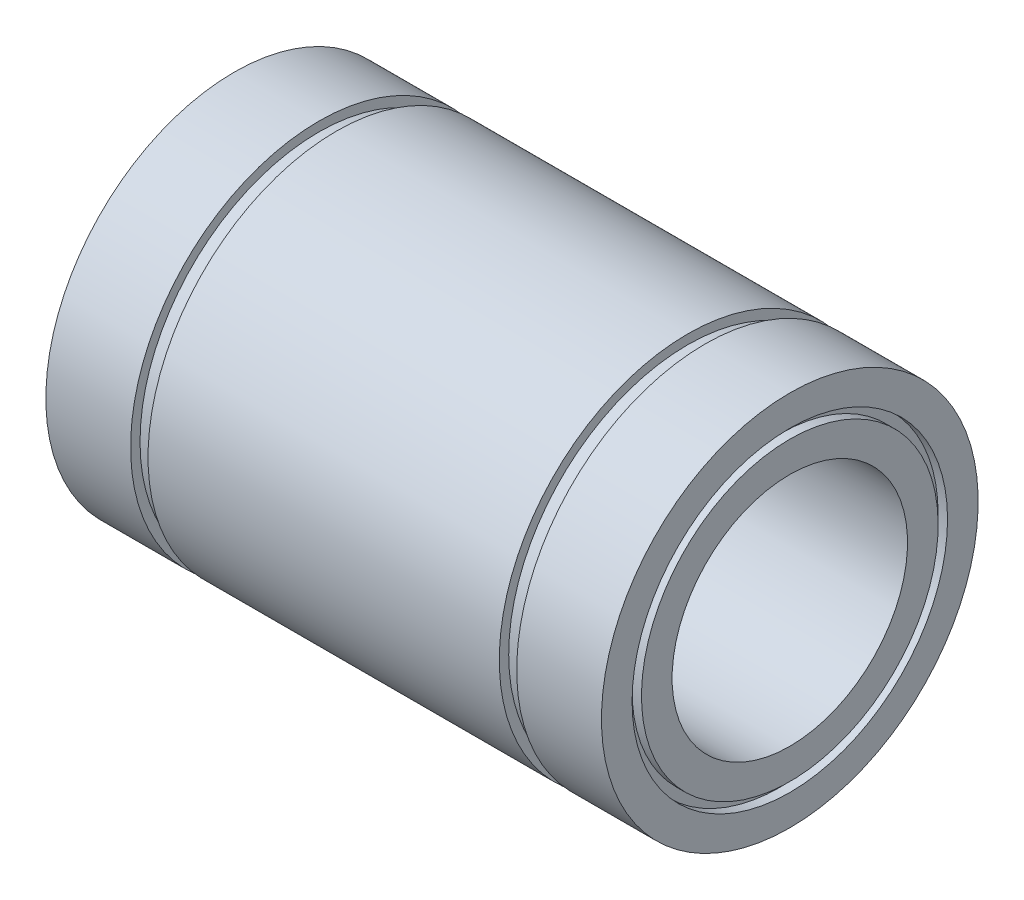
from build123d import *


with BuildPart() as part:
    # Esboço1 → Revolução1 (revolve)
    with BuildSketch(Plane.XY):
        Polygon((-29.5, 20), (-20.5, 20), (-20.5, 19), (-18.65, 19), (-18.65, 20), (18.65, 20), (18.65, 19), (20.5, 19), (20.5, 20), (29.5, 20), (29.5, 16.75), (28.5, 16.75), (28.5, 15.75), (29.5, 15.75), (29.5, 12.5), (-29.5, 12.5), (-29.5, 15.75), (-28.5, 15.75), (-28.5, 16.75), (-29.5, 16.75), align=None)
    revolve(axis=Axis((0, 0, 0), (-1, 0, 0)))


solid = part.part
